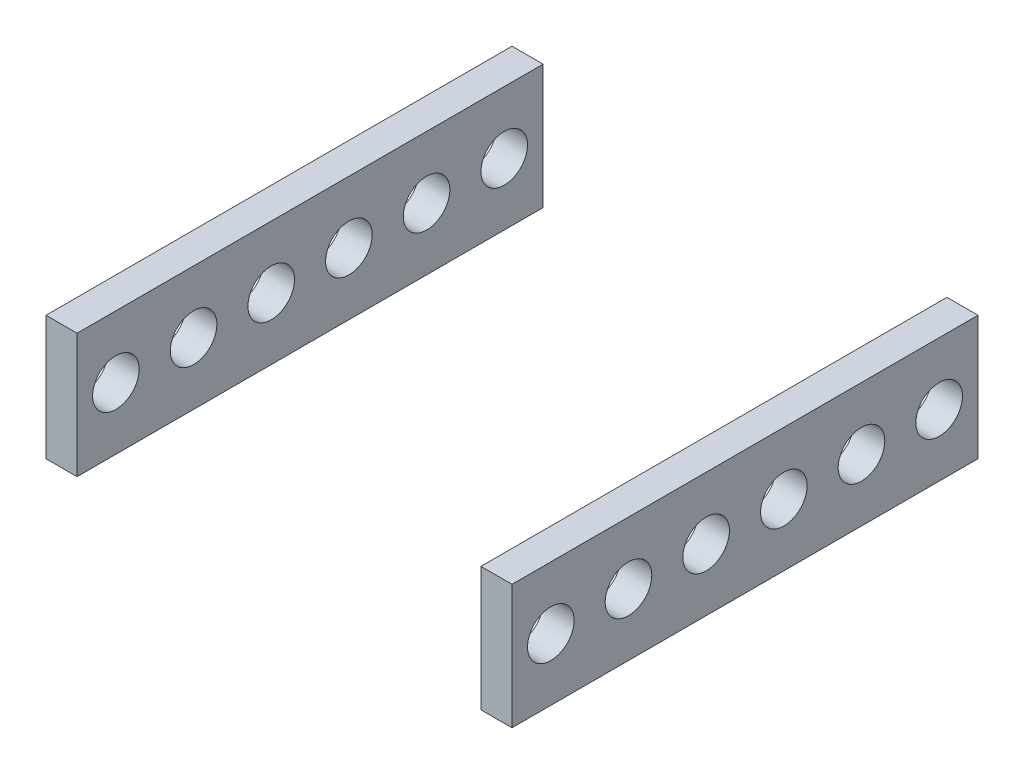
from build123d import *

# Parameters (mm, degrees)
SKETCH1_W             = 20
SKETCH1_H             = 80
BOSS_EXTRUDE1_DEPTH   = 300
BOSS_EXTRUDE1_2_DEPTH = 300
SKETCH2_R             = 15
CUT_EXTRUDE1_DEPTH    = 300
SKETCH3_R             = 15
CUT_EXTRUDE2_DEPTH    = 300
LPATTERN1_COUNT       = 6
LPATTERN1_PITCH       = 50


with BuildPart() as part:
    # Sketch1 → Boss-Extrude1 (new body)
    with BuildSketch(Plane.XY):
        with Locations((15.155083539, -10.873778004)):
            Rectangle(SKETCH1_W, SKETCH1_H)
    extrude(amount=BOSS_EXTRUDE1_DEPTH)


with BuildPart() as body_2:
    # Sketch1 → Boss-Extrude1 2 (new body)
    with BuildSketch(Plane.XY):
        with Locations((-264.83213886, -10.873778004)):
            Rectangle(SKETCH1_W, SKETCH1_H)
    extrude(amount=BOSS_EXTRUDE1_2_DEPTH)


with BuildPart() as cut_extrude1_tool:
    # Sketch2 → Cut-Extrude1 (new body)
    with BuildSketch(Plane.ZY.offset(274.83213886)):
        with Locations((25, -10.873778004)):
            Circle(SKETCH2_R)
    cut_extrude1 = extrude(amount=-CUT_EXTRUDE1_DEPTH)


with BuildPart() as part_1:
    add(part.part)

    # Cut-Extrude1: cut by cut_extrude1_tool
    add(cut_extrude1_tool.part, mode=Mode.SUBTRACT)


with BuildPart() as body_2_1:
    add(body_2.part)

    # Cut-Extrude1: cut by cut_extrude1_tool
    add(cut_extrude1_tool.part, mode=Mode.SUBTRACT)


with BuildPart() as cut_extrude2_tool:
    # Sketch3 → Cut-Extrude2 (new body)
    with BuildSketch(Plane.ZY.offset(274.83213886)):
        with Locations((275, -10.873778004)):
            Circle(SKETCH3_R)
    extrude(amount=-CUT_EXTRUDE2_DEPTH)


with BuildPart() as part_2:
    add(part_1.part)

    # Cut-Extrude2: cut by cut_extrude2_tool
    add(cut_extrude2_tool.part, mode=Mode.SUBTRACT)


with BuildPart() as body_2_2:
    add(body_2_1.part)

    # Cut-Extrude2: cut by cut_extrude2_tool
    add(cut_extrude2_tool.part, mode=Mode.SUBTRACT)


with BuildPart() as lpattern1_tool:
    # LPattern1: Cut-Extrude1 ×6
    with Locations(*[(0, 0, i * LPATTERN1_PITCH) for i in range(1, LPATTERN1_COUNT)]):
        add(cut_extrude1)


with BuildPart() as part_3:
    add(part_2.part)

    # LPattern1: cut by lpattern1_tool
    add(lpattern1_tool.part, mode=Mode.SUBTRACT)


with BuildPart() as body_2_3:
    add(body_2_2.part)

    # LPattern1: cut by lpattern1_tool
    add(lpattern1_tool.part, mode=Mode.SUBTRACT)


solid = Compound([part_3.part, body_2_3.part])
